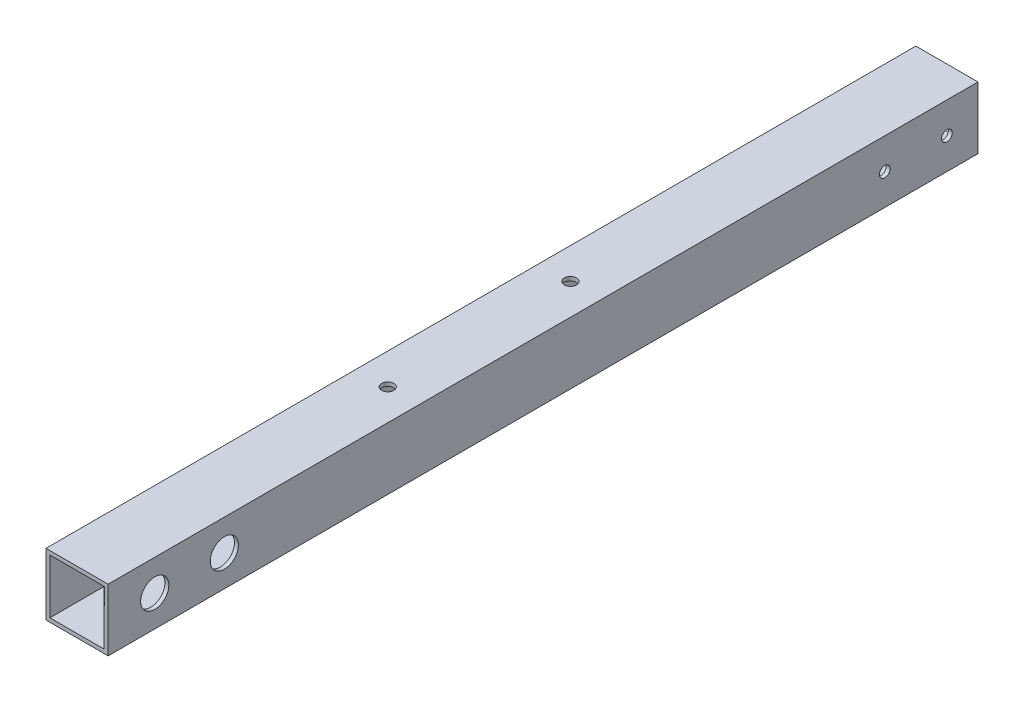
from build123d import *

# Parameters (mm, degrees)
SKETCH1_W           = 25.4
SKETCH1_H           = 25.4
SKETCH1_W_2         = 22.225
SKETCH1_H_2         = 22.225
BOSS_EXTRUDE1_DEPTH = 355.6
SKETCH5_R           = 2.4892
CUT_EXTRUDE2_DEPTH  = 2.54
SKETCH6_R           = 5.715
CUT_EXTRUDE3_DEPTH  = 6.35
SKETCH7_R           = 2.4892
CUT_EXTRUDE4_DEPTH  = 2.54
SKETCH8_R           = 5.75437
CUT_EXTRUDE5_DEPTH  = 2.54
SKETCH10_R          = 2.1828125
CUT_EXTRUDE7_DEPTH  = 25.4


with BuildPart() as part:
    # Sketch1 → Boss-Extrude1 (new body)
    with BuildSketch(Plane.XY):
        Rectangle(SKETCH1_W, SKETCH1_H)
        Rectangle(SKETCH1_W_2, SKETCH1_H_2, mode=Mode.SUBTRACT)
    extrude(amount=BOSS_EXTRUDE1_DEPTH)

    # Sketch5 → Cut-Extrude2 (cut)
    with BuildSketch(Plane.ZY.offset(12.7)):
        with Locations((336.55, 0)):
            Circle(SKETCH5_R)
        with Locations((308.102, 0)):
            Circle(SKETCH5_R)
    extrude(amount=-CUT_EXTRUDE2_DEPTH, mode=Mode.SUBTRACT)

    # Sketch6 → Cut-Extrude3 (cut)
    with BuildSketch(Plane.XZ.offset(12.7)):
        with Locations((0, 228.6)):
            Circle(SKETCH6_R)
        with Locations((0, 153.924)):
            Circle(SKETCH6_R)
    extrude(amount=-CUT_EXTRUDE3_DEPTH, mode=Mode.SUBTRACT)

    # Sketch7 → Cut-Extrude4 (cut)
    with BuildSketch(Plane(origin=(0, 12.7, 0), x_dir=(1, 0, 0), z_dir=(0, 1, 0))):
        with Locations((0, -228.6)):
            Circle(SKETCH7_R)
        with Locations((0, -153.924)):
            Circle(SKETCH7_R)
    extrude(amount=-CUT_EXTRUDE4_DEPTH, mode=Mode.SUBTRACT)

    # Sketch8 → Cut-Extrude5 (cut)
    with BuildSketch(Plane(origin=(12.7, 0, 0), x_dir=(0, 0, -1), z_dir=(1, 0, 0))):
        with Locations((-336.55, 0)):
            Circle(SKETCH8_R)
        with Locations((-308.102, 0)):
            Circle(SKETCH8_R)
    extrude(amount=-CUT_EXTRUDE5_DEPTH, mode=Mode.SUBTRACT)

    # Sketch10 → Cut-Extrude7 (cut)
    with BuildSketch(Plane.ZY.offset(12.7)):
        with Locations((12.7, 0)):
            Circle(SKETCH10_R)
        with Locations((38.1, 0)):
            Circle(SKETCH10_R)
    extrude(amount=-CUT_EXTRUDE7_DEPTH, mode=Mode.SUBTRACT)


solid = part.part
